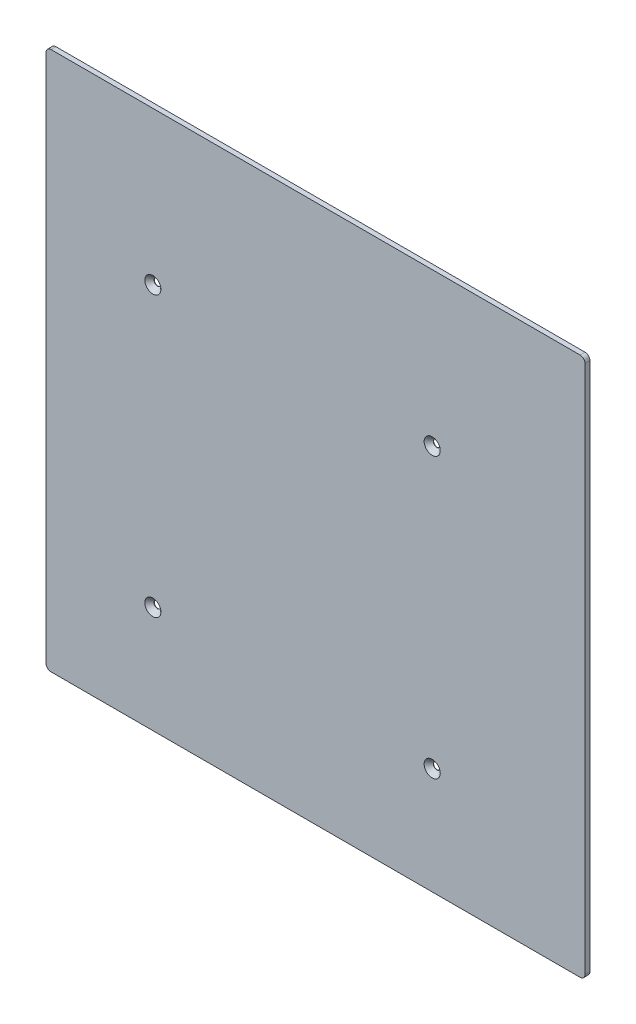
from build123d import *

# Parameters (mm, degrees)
SKETCH1_W                                      = 328
SKETCH1_H                                      = 328
BOSS_EXTRUDE1_DEPTH                            = 3
SKETCH2_W                                      = 28.812164255
SKETCH2_H                                      = 11.449209801
CUT_EXTRUDE1_DEPTH                             = 0.5
CSK_FOR_M3_5_FLAT_HEAD_MACHINE_SCREW1_AT_COUNT = 2
CSK_FOR_M3_5_FLAT_HEAD_MACHINE_SCREW1_AT_PITCH = 170
CSK_FOR_M3_5_FLAT_HEAD_MACHINE_SCREW_2_COUNT   = 2
CSK_FOR_M3_5_FLAT_HEAD_MACHINE_SCREW_2_PITCH   = 240.416305603
CSK_FOR_M3_5_FLAT_HEAD_MACHINE_SCREW_3_COUNT   = 2
CSK_FOR_M3_5_FLAT_HEAD_MACHINE_SCREW_3_PITCH   = 170
FILLET1_R                                      = 3


with BuildPart() as part:
    # Sketch1 → Boss-Extrude1 (new body)
    with BuildSketch(Plane(origin=(0, 0, 0), x_dir=(-1, 0, 0), z_dir=(0, 0, -1))):
        with Locations((-14, 14)):
            Rectangle(SKETCH1_W, SKETCH1_H)
    extrude(amount=-BOSS_EXTRUDE1_DEPTH)

    # Sketch2 → Cut-Extrude1 (cut)
    with BuildSketch(Plane(origin=(0, 0, 0), x_dir=(-1, 0, 0), z_dir=(0, 0, -1))):
        with Locations((87.056843615, 111.7753951)):
            Rectangle(SKETCH2_W, SKETCH2_H)
    extrude(amount=-CUT_EXTRUDE1_DEPTH, mode=Mode.SUBTRACT)

    # Sketch3 → CSK for M3.5 Flat Head Machine Screw1 (revolve, cut)
    with BuildSketch(Plane(origin=(-85, -85, 3), x_dir=(0, -1, 0), z_dir=(1, 0, 0))):
        Polygon((0, 0), (0, 3), (2.1, 3), (2.1, 2.8), (4.9, 0), align=None)
    csk_for_m3_5_flat_head_machine_screw1 = revolve(axis=Axis((-85, -85, 9.35), (0, 0, -1)), mode=Mode.SUBTRACT)

    # CSK for M3.5 Flat Head Machine Screw1 at: CSK for M3.5 Flat Head Machine Screw1 ×2
    with Locations(*[(i * CSK_FOR_M3_5_FLAT_HEAD_MACHINE_SCREW1_AT_PITCH, 0, 0) for i in range(1, CSK_FOR_M3_5_FLAT_HEAD_MACHINE_SCREW1_AT_COUNT)]):
        add(csk_for_m3_5_flat_head_machine_screw1, mode=Mode.SUBTRACT)

    # CSK for M3.5 Flat Head Machine Screw 2: CSK for M3.5 Flat Head Machine Screw1 ×2
    with Locations(*[Vector(0.707106781, 0.707106781, 0) * (i * CSK_FOR_M3_5_FLAT_HEAD_MACHINE_SCREW_2_PITCH) for i in range(1, CSK_FOR_M3_5_FLAT_HEAD_MACHINE_SCREW_2_COUNT)]):
        add(csk_for_m3_5_flat_head_machine_screw1, mode=Mode.SUBTRACT)

    # CSK for M3.5 Flat Head Machine Screw 3: CSK for M3.5 Flat Head Machine Screw1 ×2
    with Locations(*[(0, i * CSK_FOR_M3_5_FLAT_HEAD_MACHINE_SCREW_3_PITCH, 0) for i in range(1, CSK_FOR_M3_5_FLAT_HEAD_MACHINE_SCREW_3_COUNT)]):
        add(csk_for_m3_5_flat_head_machine_screw1, mode=Mode.SUBTRACT)

    # Fillet1
    fillet1_edges = [part.edges().sort_by_distance(p)[0] for p in [
        (178, -150, 1.5),
        (178, 178, 1.5),
        (-150, 178, 1.5),
        (-150, -150, 1.5),
    ]]
    fillet(fillet1_edges, radius=FILLET1_R)


solid = part.part
